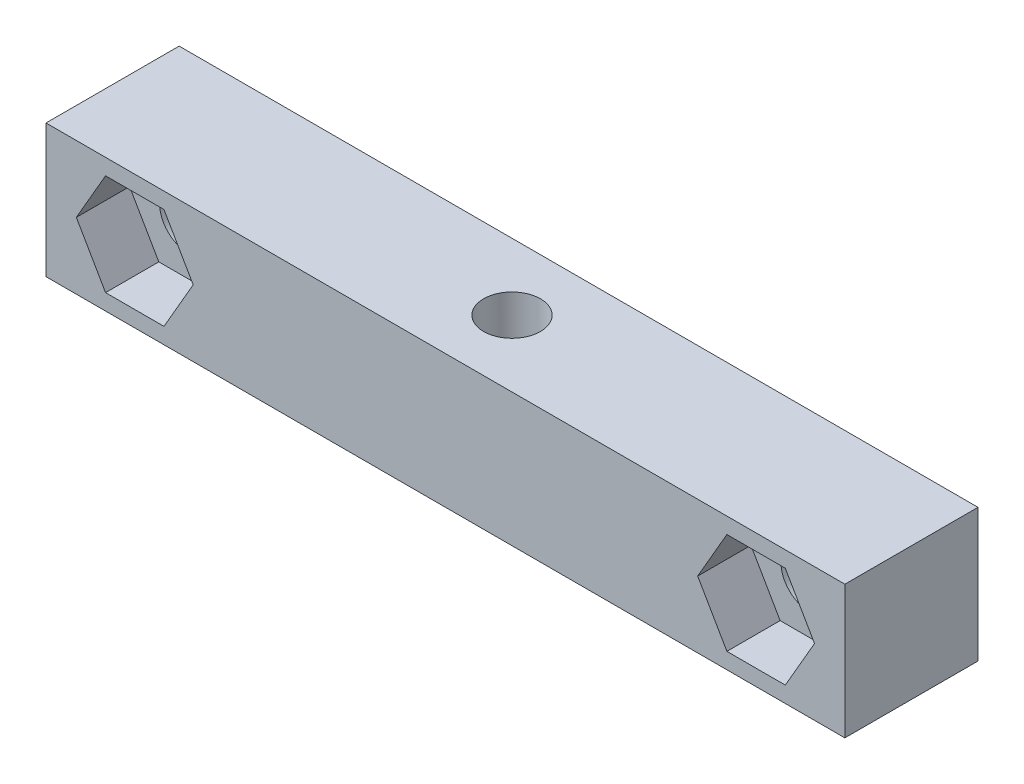
from build123d import *

# Parameters (mm, degrees)
CROQUIS1_W              = 45
CROQUIS1_H              = 7.5
CROQUIS1_R              = 1.6
SALIENTE_EXTRUIR1_DEPTH = 7.5
CORTAR_EXTRUIR1_REACH   = 9.5
CROQUIS2_R              = 1.6
CORTAR_EXTRUIR2_DEPTH   = 3
CORTAR_EXTRUIR3_DEPTH   = 3


with BuildPart() as part:
    # Croquis1 → Saliente-Extruir1 (new body)
    with BuildSketch(Plane.XY):
        Rectangle(CROQUIS1_W, CROQUIS1_H)
        with Locations((-17.5, 0)):
            Circle(CROQUIS1_R, mode=Mode.SUBTRACT)
        with Locations((17.5, 0)):
            Circle(CROQUIS1_R, mode=Mode.SUBTRACT)
    extrude(amount=SALIENTE_EXTRUIR1_DEPTH)

    # Croquis2 → Cortar-Extruir1 (cut, up to next)
    with BuildSketch(Plane(origin=(0, 3.75, 0), x_dir=(1, 0, 0), z_dir=(0, 1, 0)), mode=Mode.PRIVATE) as cortar_extruir1_sk1:
        with Locations((0, -3.75)):
            Circle(CROQUIS2_R)
    cortar_extruir1_tool1 = extrude(cortar_extruir1_sk1.sketch, amount=-CORTAR_EXTRUIR1_REACH, mode=Mode.PRIVATE) & part.part
    add(cortar_extruir1_tool1.solids().sort_by_distance((0, 3.75, 3.75))[0], mode=Mode.SUBTRACT)

    # Croquis3 → Cortar-Extruir2 (cut)
    with BuildSketch(Plane.XZ.offset(3.75)):
        Polygon((3.290896534, 3.75), (1.645448267, 6.6), (-1.645448267, 6.6), (-3.290896534, 3.75), (-1.645448267, 0.9), (1.645448267, 0.9), align=None)
    extrude(amount=-CORTAR_EXTRUIR2_DEPTH, mode=Mode.SUBTRACT)

    # Croquis4 → Cortar-Extruir3 (cut)
    with BuildSketch(Plane.XY.offset(7.5)):
        Polygon((-14.209103466, 0), (-15.854551733, 2.85), (-19.145448267, 2.85), (-20.790896534, 0), (-19.145448267, -2.85), (-15.854551733, -2.85), align=None)
        Polygon((20.790896534, 0), (19.145448267, 2.85), (15.854551733, 2.85), (14.209103466, 0), (15.854551733, -2.85), (19.145448267, -2.85), align=None)
    extrude(amount=-CORTAR_EXTRUIR3_DEPTH, mode=Mode.SUBTRACT)


solid = part.part
